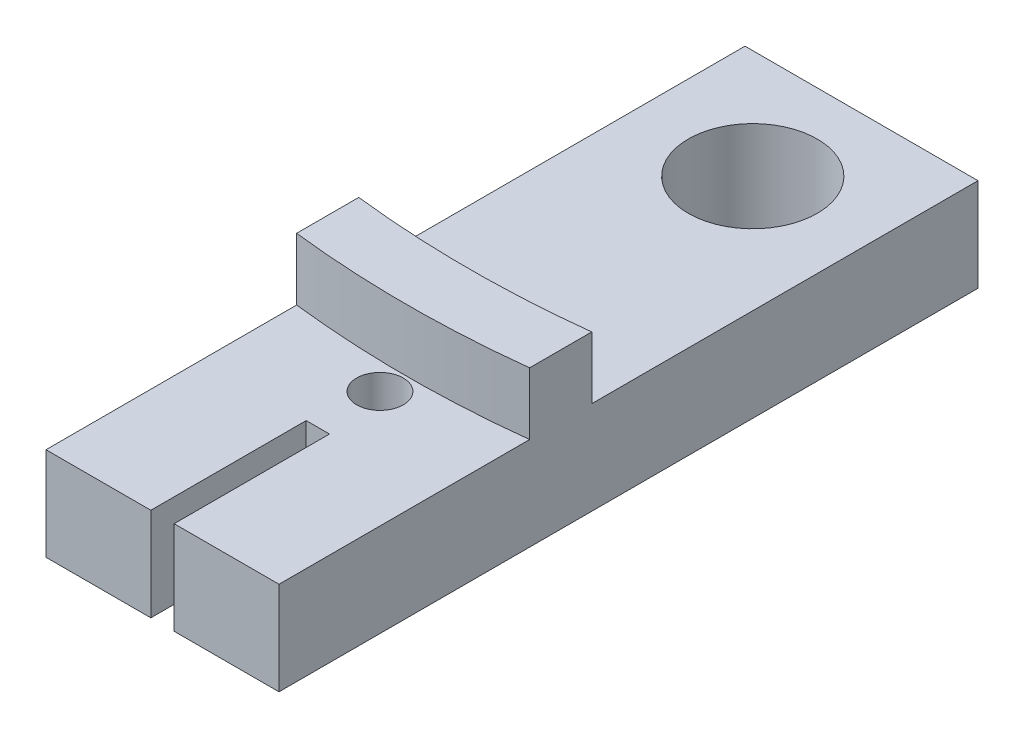
from build123d import *

# Parameters (mm, degrees)
SKETCH1_W           = 15
SKETCH1_H           = 35
SKETCH1_R           = 4.15
SKETCH1_R_2         = 1.5
BOSS_EXTRUDE1_DEPTH = 6
BOSS_EXTRUDE2_DEPTH = 4
SKETCH3_W           = 6.75
SKETCH3_H           = 6
BOSS_EXTRUDE3_DEPTH = 10


with BuildPart() as part:
    # Sketch1 → Boss-Extrude1 (new body)
    with BuildSketch(Plane(origin=(0, 0, 0), x_dir=(1, 0, 0), z_dir=(0, 1, 0))):
        Rectangle(SKETCH1_W, SKETCH1_H)
        with Locations(Location((0, 10.5, 0), (0, 0, 270))):  # turned: the seam where the file's is
            Circle(SKETCH1_R, mode=Mode.SUBTRACT)
        with Locations(Location((0, -13.5, 0), (0, 0, 270))):  # turned: the seam where the file's is
            Circle(SKETCH1_R_2, mode=Mode.SUBTRACT)
    extrude(amount=BOSS_EXTRUDE1_DEPTH)

    # Sketch2 → Boss-Extrude2 (add)
    with BuildSketch(Plane(origin=(0, 6, 0), x_dir=(1, 0, 0), z_dir=(0, 1, 0))):
        with BuildLine():
            Line((-7.5, -11.365857851), (-7.5, -7.365857851))
            ThreePointArc((-7.5, -7.365857851), (0, -7.8), (7.5, -7.365857851))
            Line((7.5, -7.365857851), (7.5, -11.365857851))
            ThreePointArc((7.5, -11.365857851), (0, -11.8), (-7.5, -11.365857851))
        make_face()
    extrude(amount=BOSS_EXTRUDE2_DEPTH)

    # Sketch3 → Boss-Extrude3 (add)
    with BuildSketch(Plane.XY.offset(17.5)):
        with Locations((4.125, 3)):
            Rectangle(SKETCH3_W, SKETCH3_H)
        with Locations((-4.125, 3)):
            Rectangle(SKETCH3_W, SKETCH3_H)
    extrude(amount=BOSS_EXTRUDE3_DEPTH)


solid = part.part
